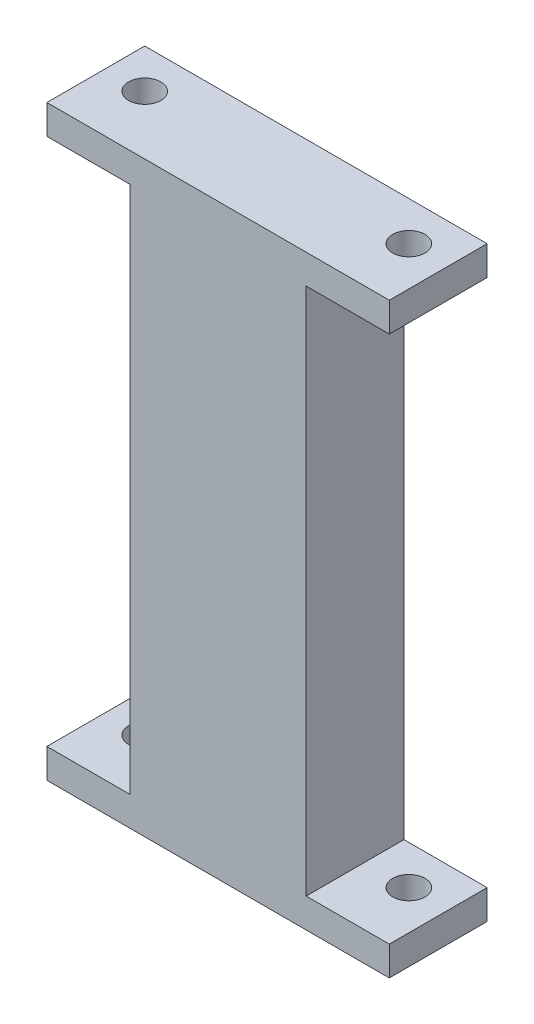
from build123d import *

# Parameters (mm, degrees)
SKETCH1_W           = 35
SKETCH1_H           = 10
BOSS_EXTRUDE1_DEPTH = 1.5
SKETCH2_R           = 1.65
CUT_EXTRUDE1_DEPTH  = 3
SKETCH3_W           = 18
SKETCH3_H           = 10
BOSS_EXTRUDE2_DEPTH = 54


with BuildPart() as part:
    # Sketch1 → Boss-Extrude1 (new body, symmetric)
    with BuildSketch(Plane(origin=(0, 0, 0), x_dir=(1, 0, 0), z_dir=(0, 1, 0))):
        Rectangle(SKETCH1_W, SKETCH1_H)
    boss_extrude1 = extrude(amount=BOSS_EXTRUDE1_DEPTH, both=True)

    # Sketch2 → Cut-Extrude1 (cut)
    with BuildSketch(Plane(origin=(0, 1.5, 0), x_dir=(1, 0, 0), z_dir=(0, 1, 0))):
        with Locations((-13.5, 1)):
            Circle(SKETCH2_R)
        with Locations((13.5, 1)):
            Circle(SKETCH2_R)
    cut_extrude1 = extrude(amount=-CUT_EXTRUDE1_DEPTH, mode=Mode.SUBTRACT)

    # Sketch3 → Boss-Extrude2 (add)
    with BuildSketch(Plane(origin=(0, 1.5, 0), x_dir=(1, 0, 0), z_dir=(0, 1, 0))):
        Rectangle(SKETCH3_W, SKETCH3_H)
    extrude(amount=BOSS_EXTRUDE2_DEPTH)

    # Mirror1: Boss-Extrude1, Cut-Extrude1 across plane
    add(boss_extrude1.mirror(Plane.ZX.offset(28.5)))
    add(cut_extrude1.mirror(Plane.ZX.offset(28.5)), mode=Mode.SUBTRACT)


solid = part.part
